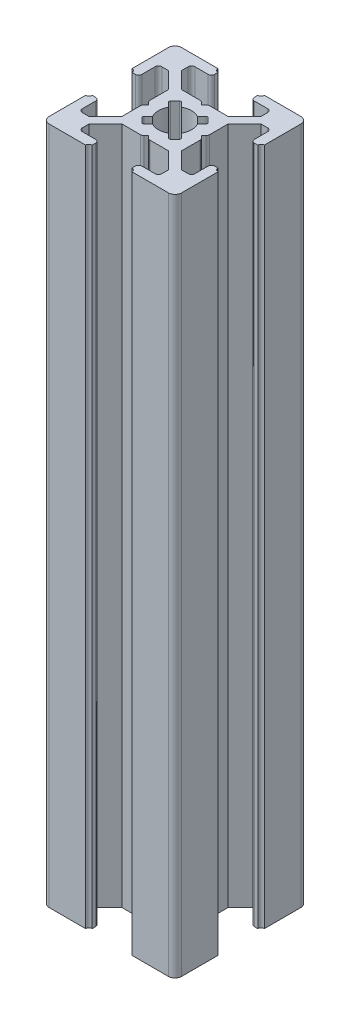
from build123d import *

# Parameters (mm, degrees)
BOSS_EXTRUDE1_DEPTH = 102.5
FILLET1_R           = 1
CUT_EXTRUDE1_DEPTH  = 103.5
FILLET2_R           = 0.5
FILLET3_R           = 0.25


with BuildPart() as part:
    # Sketch3 → Boss-Extrude1 (new body)
    with BuildSketch(Plane(origin=(0, 0, 0), x_dir=(1, 0, 0), z_dir=(0, 1, 0))):
        with BuildLine():
            Line((7, 18.5), (7, 19.5))
            ThreePointArc((7, 19.5), (6.646446609, 19.646446609), (6.5, 20))
            Line((6.5, 20), (0, 20))
            Line((0, 20), (0, 13.5))
            ThreePointArc((0, 13.5), (0.353553391, 13.353553391), (0.5, 13))
            Line((0.5, 13), (1.5, 13))
            Line((1.5, 13), (1.5, 16))
            Line((1.5, 16), (3, 16))
            Line((3, 16), (5.5, 13.5))
            Line((5.5, 13.5), (5.5, 10.5))
            Line((5.5, 10.5), (6, 10))
            Line((6, 10), (5.5, 9.5))
            Line((5.5, 9.5), (5.5, 6.5))
            Line((5.5, 6.5), (3, 4))
            Line((3, 4), (1.5, 4))
            Line((1.5, 4), (1.5, 7))
            Line((1.5, 7), (0.5, 7))
            ThreePointArc((0.5, 7), (0.353553391, 6.646446609), (0, 6.5))
            Line((0, 6.5), (0, 0))
            Line((0, 0), (6.5, 0))
            ThreePointArc((6.5, 0), (6.646446609, 0.353553391), (7, 0.5))
            Line((7, 0.5), (7, 1.5))
            Line((7, 1.5), (4, 1.5))
            Line((4, 1.5), (4, 3))
            Line((4, 3), (6.5, 5.5))
            Line((6.5, 5.5), (9.5, 5.5))
            Line((9.5, 5.5), (10, 6))
            Line((10, 6), (10.5, 5.5))
            Line((10.5, 5.5), (13.5, 5.5))
            Line((13.5, 5.5), (16, 3))
            Line((16, 3), (16, 1.5))
            Line((16, 1.5), (13, 1.5))
            Line((13, 1.5), (13, 0.5))
            ThreePointArc((13, 0.5), (13.353553391, 0.353553391), (13.5, 0))
            Line((13.5, 0), (20, 0))
            Line((20, 0), (20, 6.5))
            ThreePointArc((20, 6.5), (19.646446609, 6.646446609), (19.5, 7))
            Line((19.5, 7), (18.5, 7))
            Line((18.5, 7), (18.5, 4))
            Line((18.5, 4), (17, 4))
            Line((17, 4), (14.5, 6.5))
            Line((14.5, 6.5), (14.5, 9.5))
            Line((14.5, 9.5), (14, 10))
            Line((14, 10), (14.5, 10.5))
            Line((14.5, 10.5), (14.5, 13.5))
            Line((14.5, 13.5), (17, 16))
            Line((17, 16), (18.5, 16))
            Line((18.5, 16), (18.5, 13))
            Line((18.5, 13), (19.5, 13))
            ThreePointArc((19.5, 13), (19.646446609, 13.353553391), (20, 13.5))
            Line((20, 13.5), (20, 20))
            Line((20, 20), (13.5, 20))
            ThreePointArc((13.5, 20), (13.353553391, 19.646446609), (13, 19.5))
            Line((13, 19.5), (13, 18.5))
            Line((13, 18.5), (16, 18.5))
            Line((16, 18.5), (16, 17))
            Line((16, 17), (13.5, 14.5))
            Line((13.5, 14.5), (10.5, 14.5))
            Line((10.5, 14.5), (10, 14))
            Line((10, 14), (9.5, 14.5))
            Line((9.5, 14.5), (6.5, 14.5))
            Line((6.5, 14.5), (4, 17))
            Line((4, 17), (4, 18.5))
            Line((4, 18.5), (7, 18.5))
        make_face()
    extrude(amount=BOSS_EXTRUDE1_DEPTH)

    # Fillet1
    fillet1_edges = [part.edges().sort_by_distance(p)[0] for p in [
        (20, 51.25, 0),
        (0, 51.25, 0),
        (0, 51.25, -20),
        (20, 51.25, -20),
    ]]
    fillet(fillet1_edges, radius=FILLET1_R)

    # Sketch4 → Cut-Extrude1 (cut, through all)
    with BuildSketch(Plane(origin=(0, 102.5, 0), x_dir=(1, 0, 0), z_dir=(0, 1, 0))):
        with BuildLine():
            Line((10, 11), (11.195582496, 12.195582496))
            ThreePointArc((11.195582496, 12.195582496), (10, 12.5), (8.804417504, 12.195582496))
            Line((8.804417504, 12.195582496), (10, 11))
        make_face()
        with BuildLine():
            ThreePointArc((12.195582496, 11.195582496), (11.767766953, 11.767766953), (11.195582496, 12.195582496))
            Line((11.195582496, 12.195582496), (10, 11))
            Line((10, 11), (11, 10))
            Line((11, 10), (12.195582496, 11.195582496))
        make_face()
        with BuildLine():
            Line((9, 10), (10, 11))
            Line((10, 11), (8.804417504, 12.195582496))
            ThreePointArc((8.804417504, 12.195582496), (8.232233047, 11.767766953), (7.804417504, 11.195582496))
            Line((7.804417504, 11.195582496), (9, 10))
        make_face()
        Polygon((11, 10), (10, 11), (9, 10), (10, 9), align=None)
        with BuildLine():
            Line((7.804417504, 8.804417504), (9, 10))
            Line((9, 10), (7.804417504, 11.195582496))
            ThreePointArc((7.804417504, 11.195582496), (7.5, 10), (7.804417504, 8.804417504))
        make_face()
        with BuildLine():
            Line((10, 9), (9, 10))
            Line((9, 10), (7.804417504, 8.804417504))
            ThreePointArc((7.804417504, 8.804417504), (8.232233047, 8.232233047), (8.804417504, 7.804417504))
            Line((8.804417504, 7.804417504), (10, 9))
        make_face()
        with BuildLine():
            Line((11.195582496, 7.804417504), (10, 9))
            Line((10, 9), (8.804417504, 7.804417504))
            ThreePointArc((8.804417504, 7.804417504), (10, 7.5), (11.195582496, 7.804417504))
        make_face()
        with BuildLine():
            Line((12.195582496, 8.804417504), (11, 10))
            Line((11, 10), (10, 9))
            Line((10, 9), (11.195582496, 7.804417504))
            ThreePointArc((11.195582496, 7.804417504), (11.767766953, 8.232233047), (12.195582496, 8.804417504))
        make_face()
        with BuildLine():
            ThreePointArc((12.5, 10), (12.422700584, 10.616864556), (12.195582496, 11.195582496))
            Line((12.195582496, 11.195582496), (11, 10))
            Line((11, 10), (12.195582496, 8.804417504))
            ThreePointArc((12.195582496, 8.804417504), (12.422700584, 9.383135444), (12.5, 10))
        make_face()
        with BuildLine():
            ThreePointArc((8.804417504, 7.804417504), (8.232233047, 8.232233047), (7.804417504, 8.804417504))
            Line((7.804417504, 8.804417504), (7, 8))
            Line((7, 8), (8, 7))
            Line((8, 7), (8.804417504, 7.804417504))
        make_face()
        with BuildLine():
            Line((13, 8), (12.195582496, 8.804417504))
            ThreePointArc((12.195582496, 8.804417504), (11.767766953, 8.232233047), (11.195582496, 7.804417504))
            Line((11.195582496, 7.804417504), (12, 7))
            Line((12, 7), (13, 8))
        make_face()
        with BuildLine():
            Line((13, 12), (12, 13))
            Line((12, 13), (11.195582496, 12.195582496))
            ThreePointArc((11.195582496, 12.195582496), (11.767766953, 11.767766953), (12.195582496, 11.195582496))
            Line((12.195582496, 11.195582496), (13, 12))
        make_face()
        with BuildLine():
            ThreePointArc((7.804417504, 11.195582496), (8.232233047, 11.767766953), (8.804417504, 12.195582496))
            Line((8.804417504, 12.195582496), (8, 13))
            Line((8, 13), (7, 12))
            Line((7, 12), (7.804417504, 11.195582496))
        make_face()
    extrude(amount=-CUT_EXTRUDE1_DEPTH, mode=Mode.SUBTRACT)

    # Fillet2
    fillet2_edges = [part.edges().sort_by_distance(p)[0] for p in [
        (18.5, 51.25, -13),
        (18.5, 51.25, -16),
        (14.5, 51.25, -10.5),
        (14.5, 51.25, -9.5),
        (18.5, 51.25, -4),
        (18.5, 51.25, -7),
        (13, 51.25, -1.5),
        (16, 51.25, -1.5),
        (10.5, 51.25, -5.5),
        (9.5, 51.25, -5.5),
        (4, 51.25, -1.5),
        (7, 51.25, -1.5),
        (1.5, 51.25, -7),
        (1.5, 51.25, -4),
        (5.5, 51.25, -9.5),
        (5.5, 51.25, -10.5),
        (1.5, 51.25, -16),
        (1.5, 51.25, -13),
        (7, 51.25, -18.5),
        (4, 51.25, -18.5),
        (9.5, 51.25, -14.5),
        (10.5, 51.25, -14.5),
        (16, 51.25, -18.5),
        (13, 51.25, -18.5),
    ]]
    fillet(fillet2_edges, radius=FILLET2_R)

    # Fillet3
    fillet3_edges = [part.edges().sort_by_distance(p)[0] for p in [
        (7, 51.25, -12),
        (8, 51.25, -13),
        (12, 51.25, -13),
        (13, 51.25, -12),
        (13, 51.25, -8),
        (12, 51.25, -7),
        (8, 51.25, -7),
        (7, 51.25, -8),
    ]]
    fillet(fillet3_edges, radius=FILLET3_R)


solid = part.part
